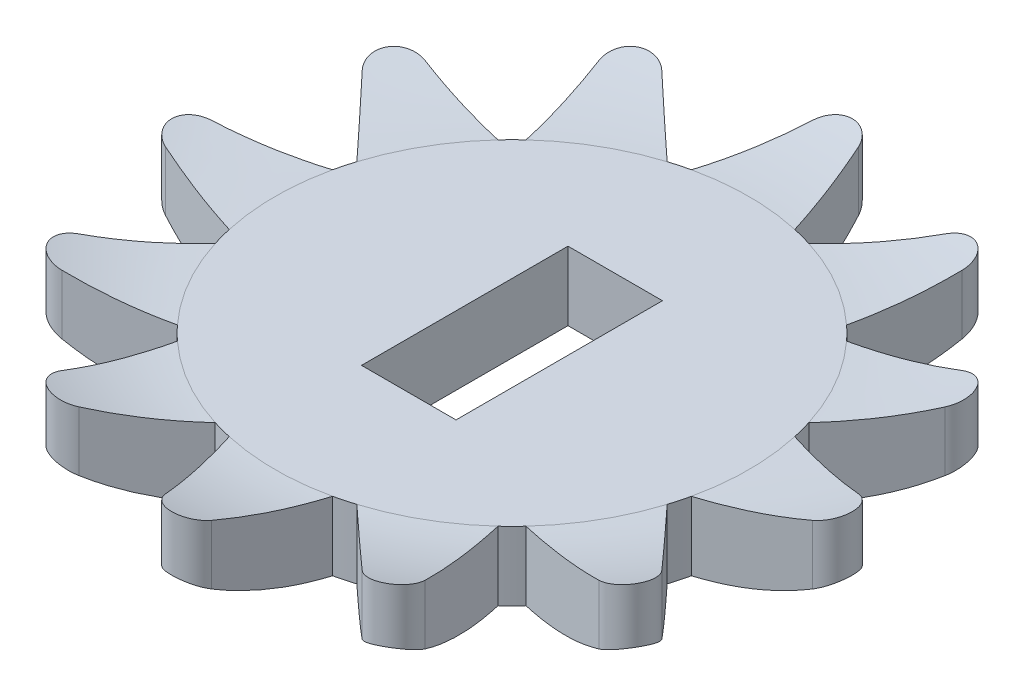
from build123d import *

# Parameters (mm, degrees)
BOSS_EXTRUDE1_DEPTH = 2.45
SKETCH7_W           = 6.875
SKETCH7_H           = 0.45
SKETCH8_W           = 2.7432
SKETCH8_H           = 5.9944
CUT_EXTRUDE1_DEPTH  = 10


with BuildPart() as part:
    # Sketch1 → Boss-Extrude1 (new body)
    with BuildSketch(Plane(origin=(0, 0, 0), x_dir=(1, 0, 0), z_dir=(0, 1, 0))):
        with BuildLine():
            Line((1.5, 6.70936845), (0.668522477, 9.387551675))
            ThreePointArc((0.668522477, 9.387551675), (0, 9.88), (-0.668522477, 9.387551675))
            Line((-0.668522477, 9.387551675), (-1.5, 6.70936845))
            ThreePointArc((-1.5, 6.70936845), (-1.779380935, 6.640740056), (-2.055646119, 6.560483521))
            Line((-2.055646119, 6.560483521), (-4.114818389, 8.464119468))
            ThreePointArc((-4.114818389, 8.464119468), (-4.94, 8.556330989), (-5.272733285, 7.795596991))
            Line((-5.272733285, 7.795596991), (-4.653722331, 5.060483521))
            ThreePointArc((-4.653722331, 5.060483521), (-4.861359121, 4.861359121), (-5.060483521, 4.653722331))
            Line((-5.060483521, 4.653722331), (-7.795596991, 5.272733285))
            ThreePointArc((-7.795596991, 5.272733285), (-8.556330989, 4.94), (-8.464119468, 4.114818389))
            Line((-8.464119468, 4.114818389), (-6.560483521, 2.055646119))
            ThreePointArc((-6.560483521, 2.055646119), (-6.640740056, 1.779380935), (-6.70936845, 1.5))
            Line((-6.70936845, 1.5), (-9.387551675, 0.668522477))
            ThreePointArc((-9.387551675, 0.668522477), (-9.88, 0), (-9.387551675, -0.668522477))
            Line((-9.387551675, -0.668522477), (-6.70936845, -1.5))
            ThreePointArc((-6.70936845, -1.5), (-6.640740056, -1.779380935), (-6.560483521, -2.055646119))
            Line((-6.560483521, -2.055646119), (-8.464119468, -4.114818389))
            ThreePointArc((-8.464119468, -4.114818389), (-8.556330989, -4.94), (-7.795596991, -5.272733285))
            Line((-7.795596991, -5.272733285), (-5.060483521, -4.653722331))
            ThreePointArc((-5.060483521, -4.653722331), (-4.861359121, -4.861359121), (-4.653722331, -5.060483521))
            Line((-4.653722331, -5.060483521), (-5.272733285, -7.795596991))
            ThreePointArc((-5.272733285, -7.795596991), (-4.94, -8.556330989), (-4.114818389, -8.464119468))
            Line((-4.114818389, -8.464119468), (-2.055646119, -6.560483521))
            ThreePointArc((-2.055646119, -6.560483521), (-1.779380935, -6.640740056), (-1.5, -6.70936845))
            Line((-1.5, -6.70936845), (-0.668522477, -9.387551675))
            ThreePointArc((-0.668522477, -9.387551675), (0, -9.88), (0.668522477, -9.387551675))
            Line((0.668522477, -9.387551675), (1.5, -6.70936845))
            ThreePointArc((1.5, -6.70936845), (1.779380935, -6.640740056), (2.055646119, -6.560483521))
            Line((2.055646119, -6.560483521), (4.114818389, -8.464119468))
            ThreePointArc((4.114818389, -8.464119468), (4.94, -8.556330989), (5.272733285, -7.795596991))
            Line((5.272733285, -7.795596991), (4.653722331, -5.060483521))
            ThreePointArc((4.653722331, -5.060483521), (4.861359121, -4.861359121), (5.060483521, -4.653722331))
            Line((5.060483521, -4.653722331), (7.795596991, -5.272733285))
            ThreePointArc((7.795596991, -5.272733285), (8.556330989, -4.94), (8.464119468, -4.114818389))
            Line((8.464119468, -4.114818389), (6.560483521, -2.055646119))
            ThreePointArc((6.560483521, -2.055646119), (6.640740056, -1.779380935), (6.70936845, -1.5))
            Line((6.70936845, -1.5), (9.387551675, -0.668522477))
            ThreePointArc((9.387551675, -0.668522477), (9.88, 0), (9.387551675, 0.668522477))
            Line((9.387551675, 0.668522477), (6.70936845, 1.5))
            ThreePointArc((6.70936845, 1.5), (6.640740056, 1.779380935), (6.560483521, 2.055646119))
            Line((6.560483521, 2.055646119), (8.464119468, 4.114818389))
            ThreePointArc((8.464119468, 4.114818389), (8.556330989, 4.94), (7.795596991, 5.272733285))
            Line((7.795596991, 5.272733285), (5.060483521, 4.653722331))
            ThreePointArc((5.060483521, 4.653722331), (4.861359121, 4.861359121), (4.653722331, 5.060483521))
            Line((4.653722331, 5.060483521), (5.272733285, 7.795596991))
            ThreePointArc((5.272733285, 7.795596991), (4.94, 8.556330989), (4.114818389, 8.464119468))
            Line((4.114818389, 8.464119468), (2.055646119, 6.560483521))
            ThreePointArc((2.055646119, 6.560483521), (1.779380935, 6.640740056), (1.5, 6.70936845))
        make_face()
    extrude(amount=BOSS_EXTRUDE1_DEPTH)

    # Sketch7 → Cut-Revolve2 (revolve, cut)
    with BuildSketch(Plane.XY):
        with Locations((-3.4375, 2.225)):
            Rectangle(SKETCH7_W, SKETCH7_H)
        with BuildLine():
            Line((-6.875, 2.45), (-9.88, 2.45))
            ThreePointArc((-9.88, 2.45), (-8.394253517, 2.113123734), (-6.875, 2))
            Line((-6.875, 2), (-6.875, 2.45))
        make_face()
        with BuildLine():
            Line((-9.88, 0), (-6.875, 0))
            ThreePointArc((-6.875, 0), (-8.436451648, 0.216588585), (-9.88, 0.85))
            Line((-9.88, 0.85), (-9.88, 0))
        make_face()
    revolve(axis=Axis((0, 0, 0), (0, 1, 0)), mode=Mode.SUBTRACT)

    # Sketch8 → Cut-Extrude1 (cut)
    with BuildSketch(Plane(origin=(0, 2, 0), x_dir=(1, 0, 0), z_dir=(0, 1, 0))):
        Rectangle(SKETCH8_W, SKETCH8_H)
    extrude(amount=-CUT_EXTRUDE1_DEPTH, mode=Mode.SUBTRACT)


solid = part.part
